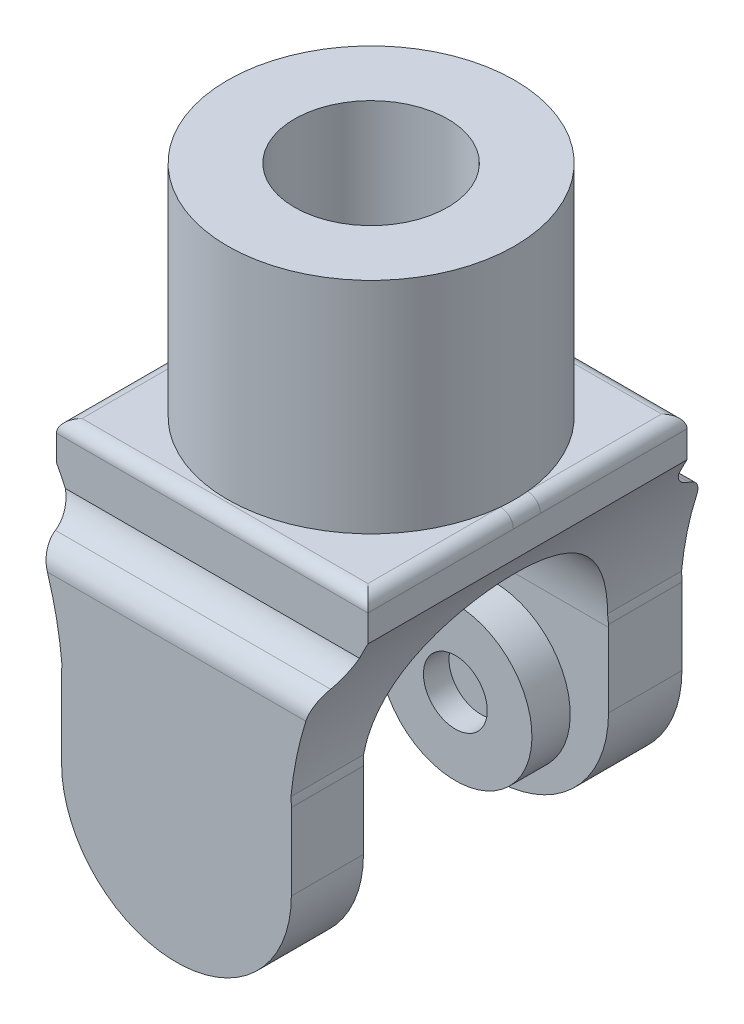
from build123d import *

# Parameters (mm, degrees)
SKETCH1_R           = 14.2875
SKETCH1_R_2         = 7.62
BOSS_EXTRUDE1_DEPTH = 21.844
SKETCH2_W           = 57.929815832
SKETCH2_H           = 52.792019068
BOSS_EXTRUDE2_DEPTH = 37.338
CUT_EXTRUDE2_DEPTH  = 53.792019068
SKETCH5_W           = 10.584509534
SKETCH5_H           = 3.93875565
SKETCH5_W_2         = 10.457509534
CUT_EXTRUDE3_DEPTH  = 37.338
FILLET2_R           = 2.54
SKETCH6_R           = 7.62
CUT_EXTRUDE4_DEPTH  = 37.338
SKETCH7_R           = 7.62
BOSS_EXTRUDE3_DEPTH = 3.81
SKETCH8_R           = 3.175
CUT_EXTRUDE5_DEPTH  = 2.54
FILLET8_R           = 1.27


with BuildPart() as part:
    # Sketch1 → Boss-Extrude1 (new body)
    with BuildSketch(Plane(origin=(0, 0, 0), x_dir=(1, 0, 0), z_dir=(0, 1, 0))):
        Circle(SKETCH1_R)
        Circle(SKETCH1_R_2, mode=Mode.SUBTRACT)
    extrude(amount=BOSS_EXTRUDE1_DEPTH)

    # Sketch2 → Boss-Extrude2 (add)
    with BuildSketch(Plane.XZ):
        Rectangle(SKETCH2_W, SKETCH2_H)
    extrude(amount=BOSS_EXTRUDE2_DEPTH)

    # Sketch4 → Cut-Extrude2 (cut, through all)
    with BuildSketch(Plane.XY.offset(26.396009534)):
        with BuildLine():
            Line((-15.494, -3.81), (-15.494, 0))
            Line((-15.494, 0), (-28.964907916, 0))
            Line((-28.964907916, 0), (-28.964907916, -37.338))
            Line((-28.964907916, -37.338), (0, -37.338))
            ThreePointArc((0, -37.338), (-8.082230509, -33.990230509), (-11.43, -25.908))
            Line((-11.43, -25.908), (-11.43, -18.288))
            ThreePointArc((-11.43, -18.288), (-11.420600472, -17.824551121), (-11.392417347, -17.361864482))
            ThreePointArc((-11.392417347, -17.361864482), (-12.761894788, -10.37972702), (-15.494, -3.81))
        make_face()
        with BuildLine():
            Line((28.964907916, 0), (15.494, 0))
            Line((15.494, 0), (15.494, -3.93875565))
            ThreePointArc((15.494, -3.93875565), (12.774357484, -10.445935023), (11.392417347, -17.361864482))
            ThreePointArc((11.392417347, -17.361864482), (11.420600472, -17.824551121), (11.43, -18.288))
            Line((11.43, -18.288), (11.43, -25.908))
            ThreePointArc((11.43, -25.908), (8.082230509, -33.990230509), (0, -37.338))
            Line((0, -37.338), (28.964907916, -37.338))
            Line((28.964907916, -37.338), (28.964907916, 0))
        make_face()
    extrude(amount=-CUT_EXTRUDE2_DEPTH, mode=Mode.SUBTRACT)

    # Sketch5 → Cut-Extrude3 (cut)
    with BuildSketch(Plane(origin=(15.494, 0, 0), x_dir=(0, 0, -1), z_dir=(1, 0, 0))):
        with BuildLine():
            Line((-15.8115, -5.588), (-15.8115, -3.93875565))
            Line((-15.8115, -3.93875565), (-26.396009534, -3.93875565))
            Line((-26.396009534, -3.93875565), (-26.396009534, -37.338))
            Line((-26.396009534, -37.338), (-19.3675, -37.338))
            Line((-19.3675, -37.338), (-19.3675, -7.9375))
            ThreePointArc((-19.3675, -7.9375), (-17.140553933, -7.44223594), (-15.8115, -5.588))
        make_face()
        with Locations((-21.103754767, -1.969377825)):
            Rectangle(SKETCH5_W, SKETCH5_H)
        with BuildLine():
            Line((-12.192, -18.542), (-12.192, -37.338))
            Line((-12.192, -37.338), (12.192, -37.338))
            Line((12.192, -37.338), (12.192, -18.542))
            ThreePointArc((12.192, -18.542), (0, -6.35), (-12.192, -18.542))
        make_face()
        with Locations((21.167254767, -1.969377825)):
            Rectangle(SKETCH5_W_2, SKETCH5_H)
        with BuildLine():
            Line((26.396009534, -3.93875565), (15.9385, -3.93875565))
            Line((15.9385, -3.93875565), (15.9385, -5.588))
            ThreePointArc((15.9385, -5.588), (17.286672159, -7.413300245), (19.4945, -7.9375))
            Line((19.4945, -7.9375), (19.4945, -37.338))
            Line((19.4945, -37.338), (26.396009534, -37.338))
            Line((26.396009534, -37.338), (26.396009534, -3.93875565))
        make_face()
    extrude(amount=-CUT_EXTRUDE3_DEPTH, mode=Mode.SUBTRACT)

    # Fillet2
    fillet2_edges = [part.edges().sort_by_distance(p)[0] for p in [
        (0.02275558, -7.9375, 19.3675),
        (0.02275558, -7.9375, -19.4945),
    ]]
    fillet(fillet2_edges, radius=FILLET2_R)

    # Sketch6 → Cut-Extrude4 (cut)
    with BuildSketch(Plane(origin=(0, 0, 0), x_dir=(1, 0, 0), z_dir=(0, 1, 0))):
        Circle(SKETCH6_R)
    extrude(amount=-CUT_EXTRUDE4_DEPTH, mode=Mode.SUBTRACT)

    # Sketch7 → Boss-Extrude3 (add)
    with BuildSketch(Plane(origin=(0, 0, 12.192), x_dir=(-1, 0, 0), z_dir=(0, 0, -1))):
        with Locations((0, -27.94)):
            Circle(SKETCH7_R)
    boss_extrude3 = extrude(amount=BOSS_EXTRUDE3_DEPTH)

    # Mirror1: Boss-Extrude3 across plane
    add(boss_extrude3.mirror(Plane.XY))

    # Sketch8 → Cut-Extrude5 (cut)
    with BuildSketch(Plane(origin=(0, 0, 8.382), x_dir=(-1, 0, 0), z_dir=(0, 0, -1))):
        with Locations((0, -27.94)):
            Circle(SKETCH8_R)
    cut_extrude5 = extrude(amount=-CUT_EXTRUDE5_DEPTH, mode=Mode.SUBTRACT)

    # Mirror2: Cut-Extrude5 across plane
    add(cut_extrude5.mirror(Plane.XY), mode=Mode.SUBTRACT)

    # Fillet8
    fillet8_edges = [part.edges().sort_by_distance(p)[0] for p in [
        (0, 0, 15.8115),
        (0, 0, -15.9385),
        (15.494, 0, -0.0635),
        (-15.494, 0, -0.0635),
    ]]
    fillet(fillet8_edges, radius=FILLET8_R)


solid = part.part
